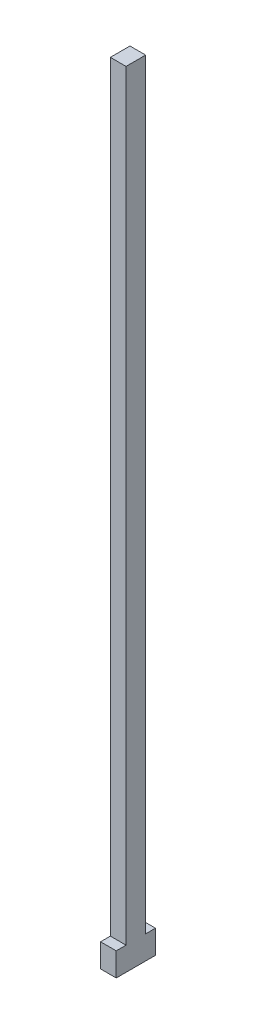
from build123d import *

# Parameters (mm, degrees)
SKETCH1_W             = 4
SKETCH1_H             = 2.501095517
BOSS_EXTRUDE1_DEPTH   = 6
SKETCH1_H_2           = 2.5
BOSS_EXTRUDE1_2_DEPTH = 6
SKETCH1_3_W           = 4
SKETCH1_3_H           = 5
BOSS_EXTRUDE2_DEPTH   = 200


with BuildPart() as part:
    # Sketch1 → Boss-Extrude1 (new body)
    with BuildSketch(Plane(origin=(0, 0, 0), x_dir=(1, 0, 0), z_dir=(0, 1, 0))):
        with Locations((0, -3.750547759)):
            Rectangle(SKETCH1_W, SKETCH1_H)
    extrude(amount=BOSS_EXTRUDE1_DEPTH)



with BuildPart() as body_2:
    # Sketch1 → Boss-Extrude1 2 (new body)
    with BuildSketch(Plane(origin=(0, 0, 0), x_dir=(1, 0, 0), z_dir=(0, 1, 0))):
        with Locations((0, 3.75)):
            Rectangle(SKETCH1_W, SKETCH1_H_2)
    extrude(amount=BOSS_EXTRUDE1_2_DEPTH)


with BuildPart() as part_1:
    add(part.part)

    add(body_2.part)  # Boss-Extrude2 merges body 2
    # Sketch1_3 → Boss-Extrude2 (add)
    with BuildSketch(Plane(origin=(0, 0, 0), x_dir=(1, 0, 0), z_dir=(0, 1, 0))):
        Rectangle(SKETCH1_3_W, SKETCH1_3_H)
    extrude(amount=BOSS_EXTRUDE2_DEPTH)


solid = part_1.part
